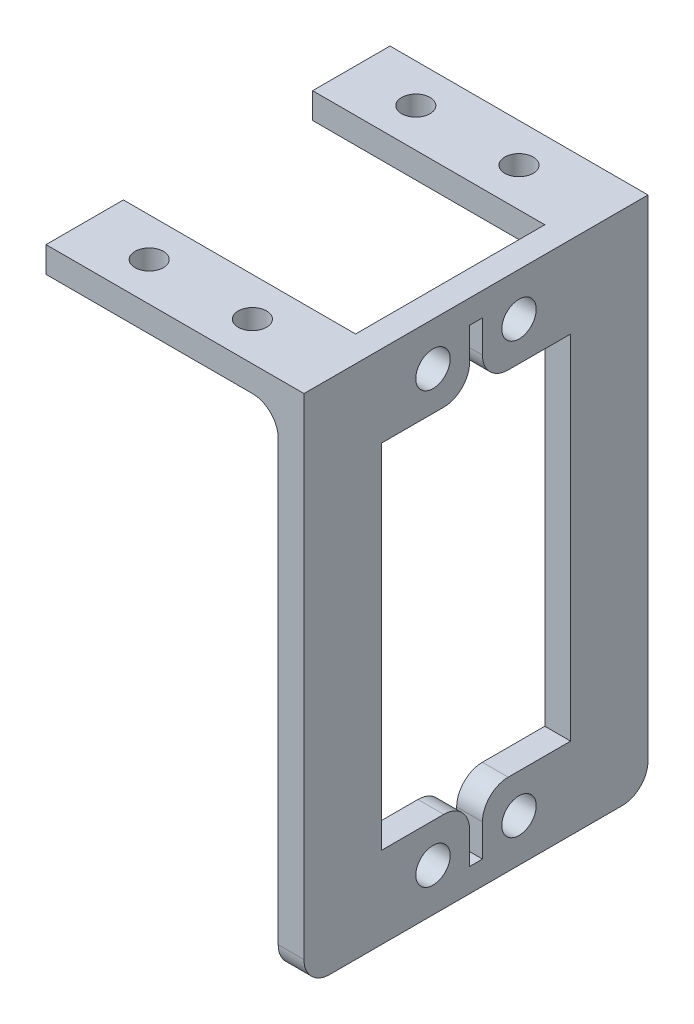
from build123d import *

# Parameters (mm, degrees)
EXTRUDE_1_DEPTH     = 40
SKETCH_2_R          = 1.65
SKETCH_2_W          = 27
SKETCH_2_H          = 22
CUT_EXTRUDE_2_DEPTH = 10
SKETCH_3_R          = 2
CUT_EXTRUDE_3_DEPTH = 10
FILLET_1_R          = 3


with BuildPart() as part:
    # 草图1 → 凸台-拉伸1 (new body)
    with BuildSketch(Plane.XY):
        Polygon((0, 0), (30, 0), (30, -60), (27, -60), (27, -3), (0, -3), align=None)
    extrude(amount=EXTRUDE_1_DEPTH)

    # 草图2 → 切除-拉伸2 (cut)
    with BuildSketch(Plane(origin=(0, 0, 0), x_dir=(1, 0, 0), z_dir=(0, 1, 0))):
        with Locations((7.5, -4.5)):
            Circle(SKETCH_2_R)
        with Locations((19.5, -4.5)):
            Circle(SKETCH_2_R)
        with Locations((19.5, -35.5)):
            Circle(SKETCH_2_R)
        with Locations((7.5, -35.5)):
            Circle(SKETCH_2_R)
        with Locations((13.5, -20)):
            Rectangle(SKETCH_2_W, SKETCH_2_H)
    extrude(amount=-CUT_EXTRUDE_2_DEPTH, mode=Mode.SUBTRACT)

    # 草图3 → 切除-拉伸3 (cut)
    with BuildSketch(Plane(origin=(30, 0, 0), x_dir=(0, 0, -1), z_dir=(1, 0, 0))):
        with Locations((-25, -5)):
            Circle(SKETCH_3_R)
        with Locations((-15, -5)):
            Circle(SKETCH_3_R)
        with Locations((-15, -55)):
            Circle(SKETCH_3_R)
        with Locations((-25, -55)):
            Circle(SKETCH_3_R)
        Polygon((-20.75, -9.5), (-20.75, -2.75), (-19.25, -2.75), (-19.25, -9.5), (-9, -9.5), (-9, -50.5), (-19.25, -50.5), (-19.25, -57.25), (-20.75, -57.25), (-20.75, -50.5), (-31, -50.5), (-31, -9.5), align=None)
    extrude(amount=-CUT_EXTRUDE_3_DEPTH, mode=Mode.SUBTRACT)

    # 圆角1
    fillet_1_edges = [part.edges().sort_by_distance(p)[0] for p in [
        (27, -3, 35.5),
        (28.5, -60, 40),
        (27, -3, 4.5),
        (28.5, -60, 0),
        (28.5, -9.5, 19.25),
        (28.5, -50.5, 19.25),
        (28.5, -50.5, 20.75),
        (28.5, -9.5, 20.75),
    ]]
    fillet(fillet_1_edges, radius=FILLET_1_R)


solid = part.part
